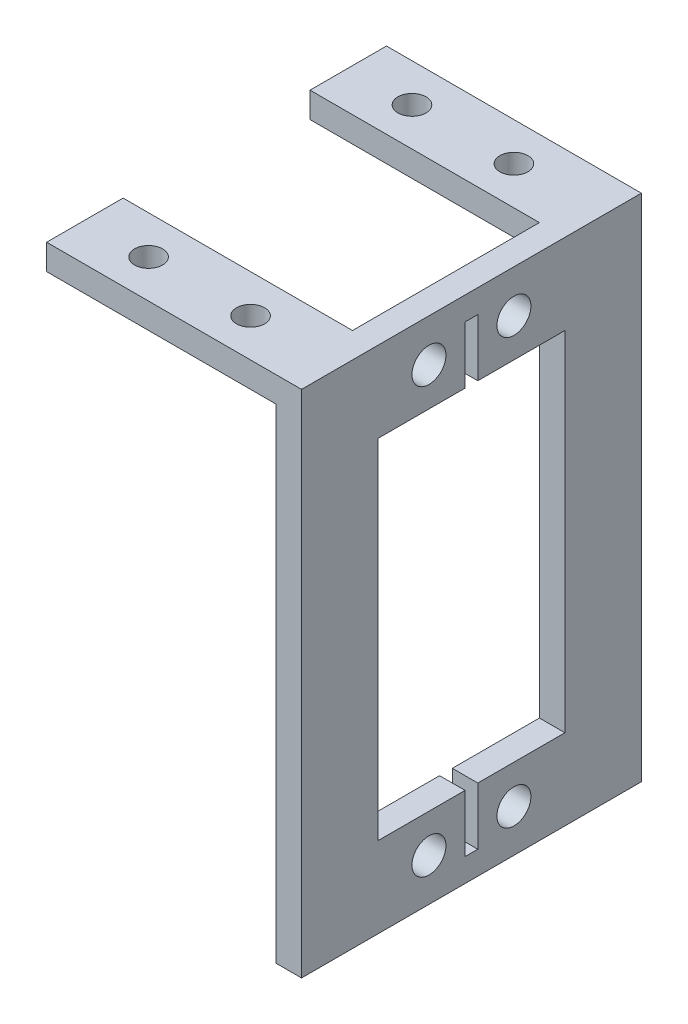
from build123d import *

# Parameters (mm, degrees)
EXTRUDE_1_DEPTH     = 40
SKETCH_2_R          = 1.65
SKETCH_2_W          = 27
SKETCH_2_H          = 22
CUT_EXTRUDE_2_DEPTH = 10
SKETCH_3_R          = 2
CUT_EXTRUDE_3_DEPTH = 10


with BuildPart() as part:
    # 草图1 → 凸台-拉伸1 (new body)
    with BuildSketch(Plane.XY):
        Polygon((0, 0), (30, 0), (30, -60), (27, -60), (27, -3), (0, -3), align=None)
    extrude(amount=EXTRUDE_1_DEPTH)

    # 草图2 → 切除-拉伸2 (cut)
    with BuildSketch(Plane(origin=(0, 0, 0), x_dir=(1, 0, 0), z_dir=(0, 1, 0))):
        with Locations((7.5, -4.5)):
            Circle(SKETCH_2_R)
        with Locations((19.5, -4.5)):
            Circle(SKETCH_2_R)
        with Locations((19.5, -35.5)):
            Circle(SKETCH_2_R)
        with Locations((7.5, -35.5)):
            Circle(SKETCH_2_R)
        with Locations((13.5, -20)):
            Rectangle(SKETCH_2_W, SKETCH_2_H)
    extrude(amount=-CUT_EXTRUDE_2_DEPTH, mode=Mode.SUBTRACT)

    # 草图3 → 切除-拉伸3 (cut)
    with BuildSketch(Plane(origin=(30, 0, 0), x_dir=(0, 0, -1), z_dir=(1, 0, 0))):
        with Locations((-25, -5)):
            Circle(SKETCH_3_R)
        with Locations((-15, -5)):
            Circle(SKETCH_3_R)
        with Locations((-15, -55)):
            Circle(SKETCH_3_R)
        with Locations((-25, -55)):
            Circle(SKETCH_3_R)
        Polygon((-20.75, -9.5), (-20.75, -2.75), (-19.25, -2.75), (-19.25, -9.5), (-9, -9.5), (-9, -50.5), (-19.25, -50.5), (-19.25, -57.25), (-20.75, -57.25), (-20.75, -50.5), (-31, -50.5), (-31, -9.5), align=None)
    extrude(amount=-CUT_EXTRUDE_3_DEPTH, mode=Mode.SUBTRACT)


solid = part.part
